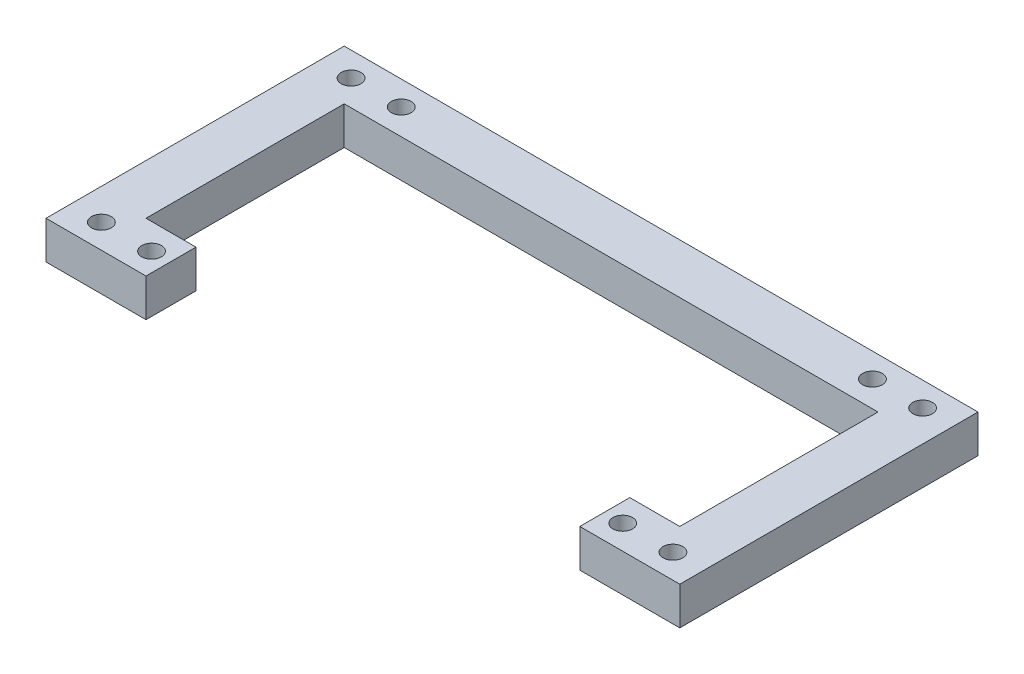
from build123d import *

# Parameters (mm, degrees)
SKETCH1_R           = 1.651
BOSS_EXTRUDE1_DEPTH = 6.35


with BuildPart() as part:
    # Sketch1 → Boss-Extrude1 (new body)
    with BuildSketch(Plane(origin=(0, 0, 0), x_dir=(1, 0, 0), z_dir=(0, 1, 0))):
        Polygon((75.155177047, 61.997896552), (75.155177047, 11.997896552), (91.919177047, 11.997896552), (91.919177047, 20.379896552), (83.537177047, 20.379896552), (83.537177047, 53.615896552), (173.037829354, 53.615896552), (173.037829354, 20.379896552), (164.655829354, 20.379896552), (164.655829354, 11.997896552), (181.419829354, 11.997896552), (181.419829354, 61.997896552), align=None)
        with Locations((80.3721812, 16.064784874)):
            Circle(SKETCH1_R, mode=Mode.SUBTRACT)
        with Locations((80.3721812, 57.93100823)):
            Circle(SKETCH1_R, mode=Mode.SUBTRACT)
        with Locations((88.7874552, 16.064784874)):
            Circle(SKETCH1_R, mode=Mode.SUBTRACT)
        with Locations((167.7875512, 57.93100823)):
            Circle(SKETCH1_R, mode=Mode.SUBTRACT)
        with Locations((88.7874552, 57.93100823)):
            Circle(SKETCH1_R, mode=Mode.SUBTRACT)
        with Locations((176.2028252, 57.93100823)):
            Circle(SKETCH1_R, mode=Mode.SUBTRACT)
        with Locations((176.2028252, 16.064784874)):
            Circle(SKETCH1_R, mode=Mode.SUBTRACT)
        with Locations((167.7875512, 16.064784874)):
            Circle(SKETCH1_R, mode=Mode.SUBTRACT)
    extrude(amount=BOSS_EXTRUDE1_DEPTH)


solid = part.part
